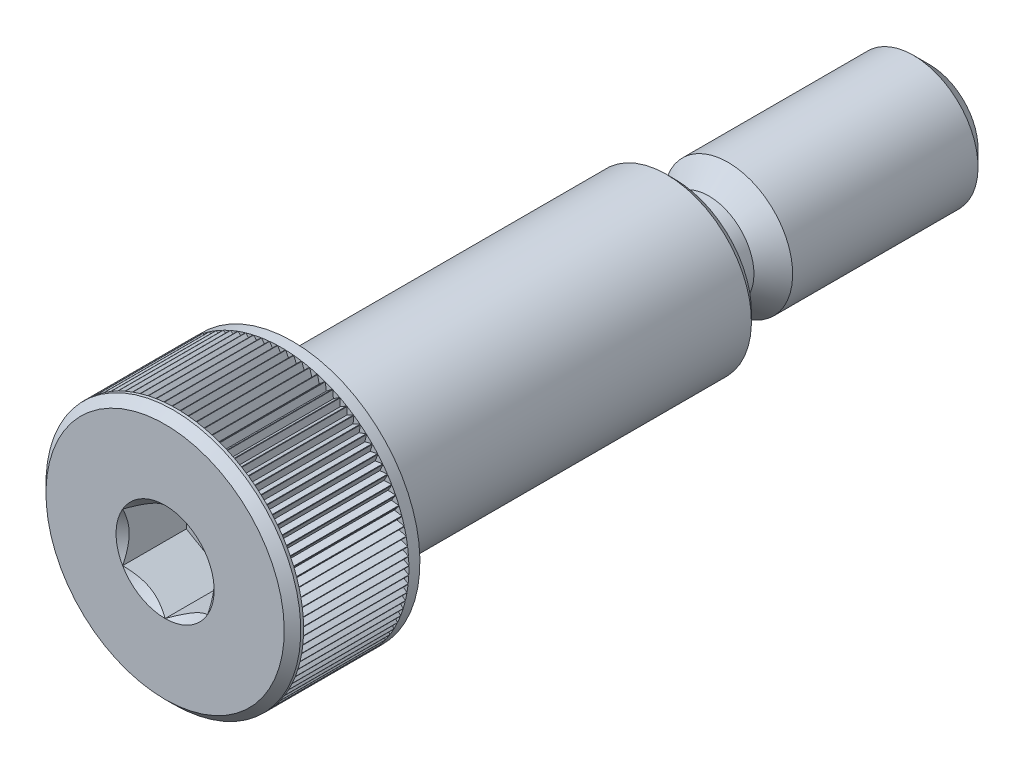
from build123d import *

# Parameters (mm, degrees)
CHAMFER1_SIZE      = 0.60325
CHAMFER2_SIZE      = 0.3095625
CUT_EXTRUDE5_DEPTH = 1.968103125
CIRPATTERN1_COUNT  = 99
CUT_EXTRUDE2_DEPTH = 2.38125


with BuildPart() as part:
    # Sketch1 → Revolve1 (revolve)
    with BuildSketch(Plane(origin=(0, 0, 0), x_dir=(0, 0, -1), z_dir=(1, 0, 0))):
        Polygon((0, 4.7625), (4.7625, 4.7625), (4.7625, 3.175), (19.05, 3.175), (19.05, 2.413), (28.575, 2.413), (28.575, 0), (0, 0), align=None)
    revolve(axis=Axis((0, 0, -28.575), (0, 0, 1)))

    # Sketch5 → Cut-Revolve1 (revolve, cut)
    with BuildSketch(Plane(origin=(0, 0, 0), x_dir=(0, 0, -1), z_dir=(1, 0, 0))):
        with BuildLine():
            Line((19.05, 3.175), (21.8059, 3.175))
            Line((21.8059, 3.175), (20.32, 1.6891))
            Line((20.32, 1.6891), (19.7739, 1.6891))
            ThreePointArc((19.7739, 1.6891), (19.262025401, 1.901125401), (19.05, 2.413))
            Line((19.05, 2.413), (19.05, 3.175))
        make_face()
    revolve(axis=Axis((0, 0, -28.575), (0, 0, 1)), mode=Mode.SUBTRACT)

    # Chamfer1
    chamfer1_edges = [part.edges().sort_by_distance(p)[0] for p in [
        (0, -2.413, -28.575),
    ]]
    chamfer(chamfer1_edges, length=CHAMFER1_SIZE)

    # Chamfer2
    chamfer2_edges = [part.edges().sort_by_distance(p)[0] for p in [
        (0, -4.7625, 0),
        (0, -3.175, -19.05),
    ]]
    chamfer(chamfer2_edges, length=CHAMFER2_SIZE)

    # Sketch11 → Cut-Extrude5 (cut, symmetric)
    with BuildSketch(Plane.XY.offset(-2.38125)):
        Polygon((0, 4.51485), (0.142980794, 4.7625), (-0.142980794, 4.7625), align=None)
    cut_extrude5 = extrude(amount=CUT_EXTRUDE5_DEPTH, both=True, mode=Mode.SUBTRACT)

    # CirPattern1: Cut-Extrude5 ×99 about axis
    cirpattern1_axis = Axis((0, 0, -28.575), (0, 0, -1))
    for i in range(1, CIRPATTERN1_COUNT):
        add(cut_extrude5.rotate(cirpattern1_axis, i * 360 / CIRPATTERN1_COUNT), mode=Mode.SUBTRACT)

    # Sketch8 → Cut-Extrude2 (cut)
    with BuildSketch(Plane.XY):
        Polygon((1.5875, 0.916543552), (0, 1.833087105), (-1.5875, 0.916543552), (-1.5875, -0.916543552), (0, -1.833087105), (1.5875, -0.916543552), align=None)
    extrude(amount=-CUT_EXTRUDE2_DEPTH, mode=Mode.SUBTRACT)

    # Cut-Extrude4 cone 1 section (through the dimple's axis) → Cut-Extrude4 (revolve, cut)
    with BuildSketch(Plane(origin=(0, 0, 0), x_dir=(0, -1, 0), z_dir=(1, 0, 0))):
        Polygon((0, 0), (1.833087105, 0), (0, 1.833087105), align=None)
    revolve(axis=Axis((0, 0, 0), (0, 0, -1)), mode=Mode.SUBTRACT)


solid = part.part
